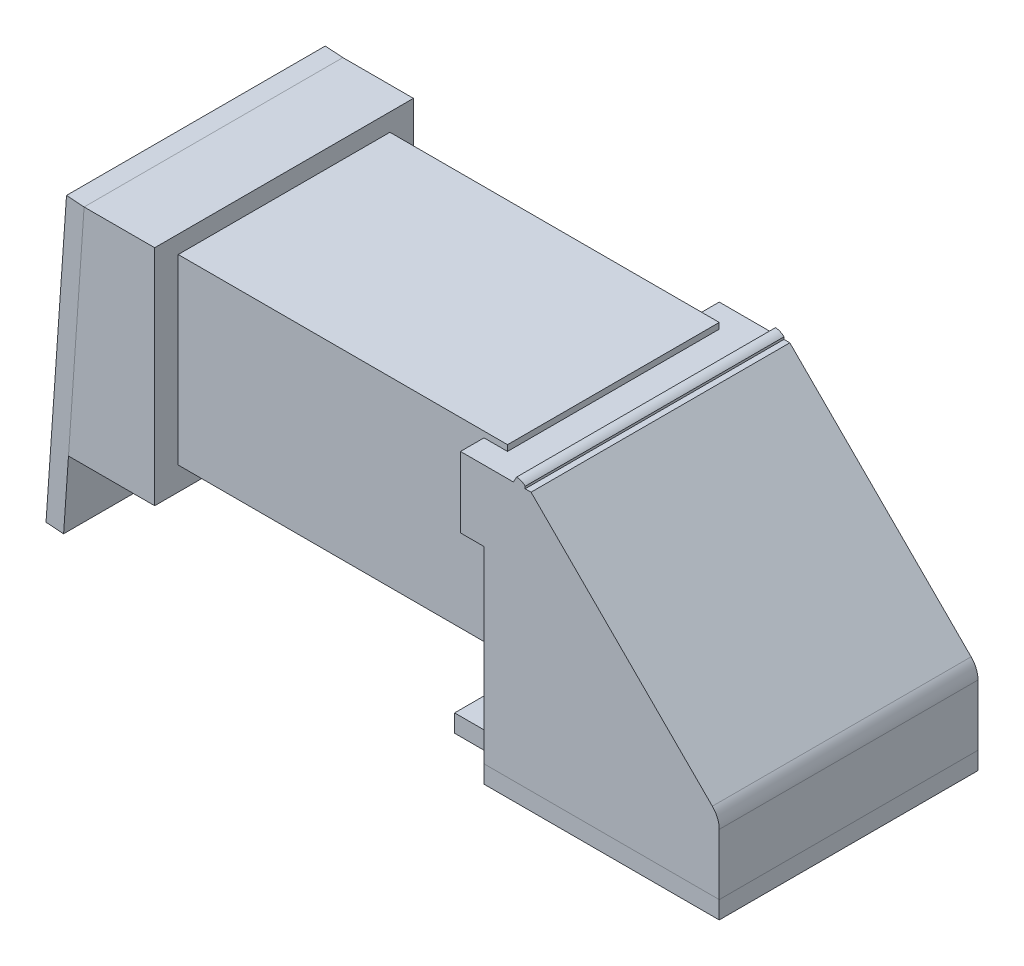
from build123d import *

# Parameters (mm, degrees)
EXTRUSION1_DEPTH  = 11
ESQUISSE3_W       = 18
ESQUISSE3_H       = 15.5
EXTRUSION2_DEPTH  = 28
ESQUISSE4_W       = 22
ESQUISSE4_H       = 19
EXTRUSION3_DEPTH  = 6
D_POUILLE1_ANGLE  = 4
COQUE1_T          = -2
ESQUISSE6_W       = 22
ESQUISSE6_H       = 25
EXTRUSION4_DEPTH  = 1.5
EXTRUSION7_DEPTH  = 22
EXTRUSION13_DEPTH = 1.5
CONG_1_R          = 2


with BuildPart() as part:
    # Esquisse2 → Extrusion1 (new body, symmetric)
    with BuildSketch(Plane.XY):
        Polygon((-20, 0), (0, 0), (0, 6), (-16, 22), (-22, 22), (-22, 16), (-20, 16), align=None)
    extrude(amount=EXTRUSION1_DEPTH, both=True)

    # Esquisse3 → Extrusion2 (add)
    with BuildSketch(Plane.ZY.offset(20)):
        with Locations((0, 14.75)):
            Rectangle(ESQUISSE3_W, ESQUISSE3_H)
    extrude(amount=EXTRUSION2_DEPTH)

    # Esquisse4 → Extrusion3 (add)
    with BuildSketch(Plane.ZY.offset(48)):
        with Locations((0, 14.5)):
            Rectangle(ESQUISSE4_W, ESQUISSE4_H)
    extrude(amount=EXTRUSION3_DEPTH)

    # Dépouille1
    d_pouille1_faces = [part.faces().sort_by_distance(p)[0] for p in [
        (-54, 14.5, 0),
    ]]
    draft(d_pouille1_faces, Plane(origin=(-54, 24, -11), x_dir=(1, 0, 0), z_dir=(0, 1, 0)), D_POUILLE1_ANGLE)

    # Coque1
    coque1_openings = [part.faces().sort_by_distance(p)[0] for p in [
        (-10, 0, 0),
    ]]
    offset(amount=COQUE1_T, openings=coque1_openings, kind=Kind.INTERSECTION)

    # Esquisse8 → Extrusion7 (add)
    with BuildSketch(Plane(origin=(0, 0, -11), x_dir=(-1, 0, 0), z_dir=(0, 0, -1))):
        with BuildLine():
            Line((16.5, 22), (16.5, 22.186687617))
            ThreePointArc((16.5, 22.186687617), (16.831154453, 22.418337524), (17.226952624, 22.5))
            Line((17.226952624, 22.5), (17.5, 22))
            Line((17.5, 22), (16.5, 22))
        make_face()
    extrude(amount=-EXTRUSION7_DEPTH)

    # Congé1
    cong_1_edges = [part.edges().sort_by_distance(p)[0] for p in [
        (0, 6, 0),
    ]]
    fillet(cong_1_edges, radius=CONG_1_R)


with BuildPart() as body_2:
    # Esquisse6 → Extrusion4 (new body)
    with BuildSketch(Plane(origin=(-55.407315068, 3.874456901, 0), x_dir=(0, 0, 1), z_dir=(-0.99756405, 0.069756474, 0))):
        with Locations((0, 7.674687624)):
            Rectangle(ESQUISSE6_W, ESQUISSE6_H)
    extrude(amount=EXTRUSION4_DEPTH)


with BuildPart() as body_3:
    # Esquisse7 → Extrusion13 (new body)
    with BuildSketch(Plane.XZ):
        Polygon((0, 11), (-20, 11), (-20, 8.5), (-25, 8.5), (-25, -8.5), (-20, -8.5), (-20, -11), (0, -11), align=None)
    extrude(amount=EXTRUSION13_DEPTH)


solid = Compound([part.part, body_2.part, body_3.part])
